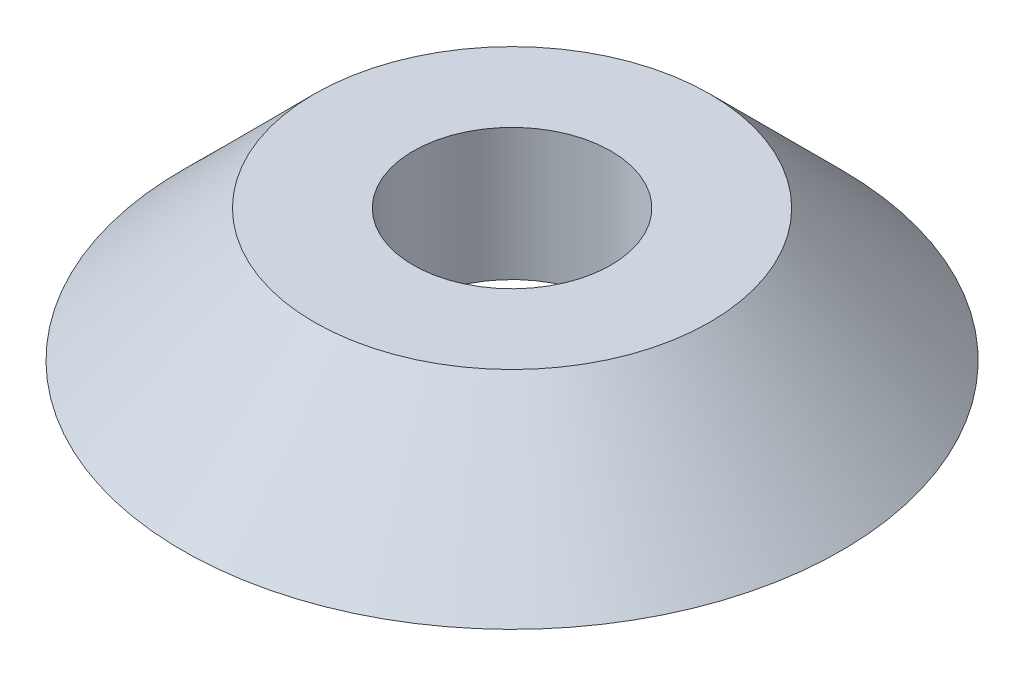
from build123d import *


with BuildPart() as part:
    # Sketch1 → Revolve1 (revolve)
    with BuildSketch(Plane.XY):
        Polygon((9.525, 0), (31.75, 0), (19.05, 12.7), (9.525, 12.7), align=None)
    revolve(axis=Axis((0, -1000.69375591, 0), (0, 1, 0)))


solid = part.part
